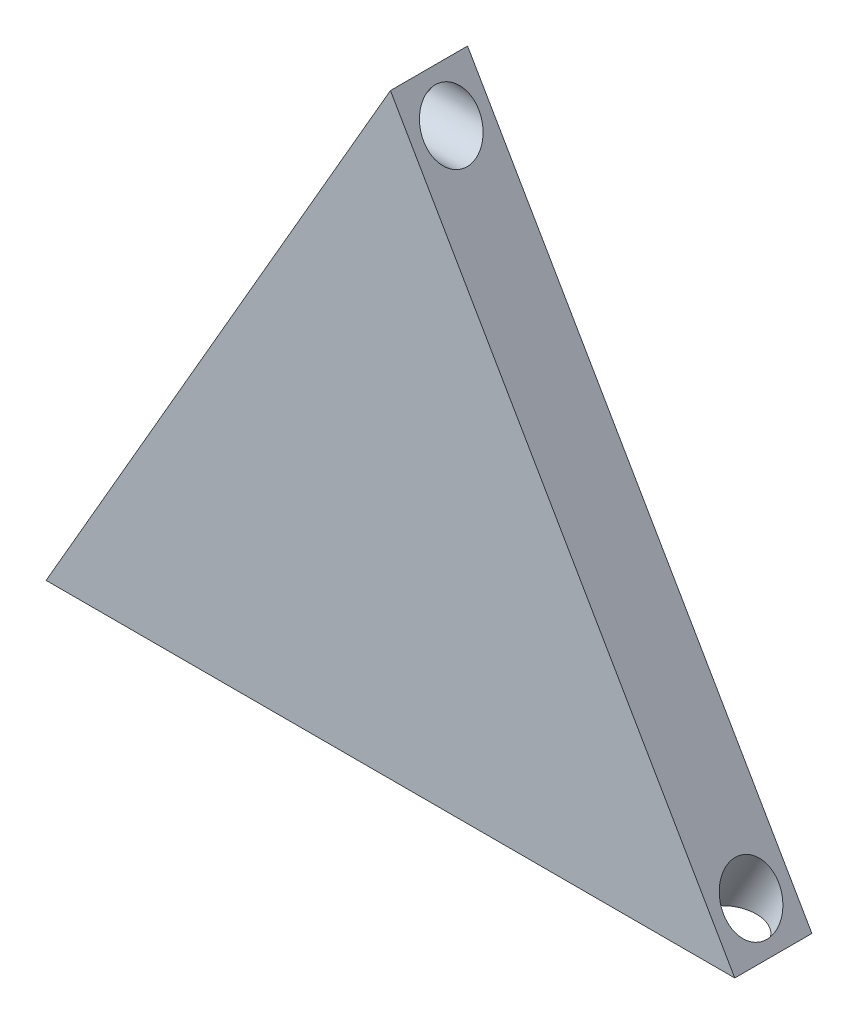
from build123d import *

# Parameters (mm, degrees)
BOSS_EXTRUDE1_DEPTH     = 14
SKETCH2_R               = 5
CUT_EXTRUDE1_DEPTH      = 50
CUT_EXTRUDE3_DEPTH      = 50
CUT_EXTRUDE3_DEPTH_BACK = 50
SKETCH5_R               = 5
CUT_EXTRUDE4_DEPTH      = 50
CUT_EXTRUDE4_DEPTH_BACK = 50
SKETCH6_R               = 5


with BuildPart() as part:
    # Sketch1 → Boss-Extrude1 (new body)
    with BuildSketch(Plane.XY):
        Polygon((-42.857142857, 0), (82.142857143, 0), (19.642857143, 108.253175473), align=None)
    extrude(amount=BOSS_EXTRUDE1_DEPTH)

    # Sketch2 → Cut-Extrude1 (cut)
    with BuildSketch(Plane(origin=(0, 0, 0), x_dir=(0, 0, -1), z_dir=(1, 0, 0))):
        with Locations((-7, 101.253175473)):
            Circle(SKETCH2_R)
    extrude(amount=CUT_EXTRUDE1_DEPTH, mode=Mode.SUBTRACT)

    # Sketch5 → Cut-Extrude3 (cut, two sides: drawn at the far end of the back side and taken through both)
    with BuildSketch(Plane(origin=(-10.714285714, 18.557687224, 0), x_dir=(-0.8660254037844386, -0.5000000000000003, 0), z_dir=(0.5000000000000003, -0.8660254037844386, 0)).offset(-CUT_EXTRUDE3_DEPTH_BACK)):
        with Locations((30.115374448, -7)):
            Circle(SKETCH5_R)
    extrude(amount=CUT_EXTRUDE3_DEPTH + CUT_EXTRUDE3_DEPTH_BACK, mode=Mode.SUBTRACT)

    # Sketch6 → Cut-Extrude4 (cut, two sides: drawn at the far end of the back side and taken through both)
    with BuildSketch(Plane(origin=(20.535714286, 35.568900513, 0), x_dir=(0.8660254037844386, -0.5000000000000003, 0), z_dir=(0.5000000000000003, 0.8660254037844386, 0)).offset(-CUT_EXTRUDE4_DEPTH_BACK)):
        with Locations((64.137801025, -7)):
            Circle(SKETCH6_R)
    extrude(amount=CUT_EXTRUDE4_DEPTH + CUT_EXTRUDE4_DEPTH_BACK, mode=Mode.SUBTRACT)


solid = part.part
